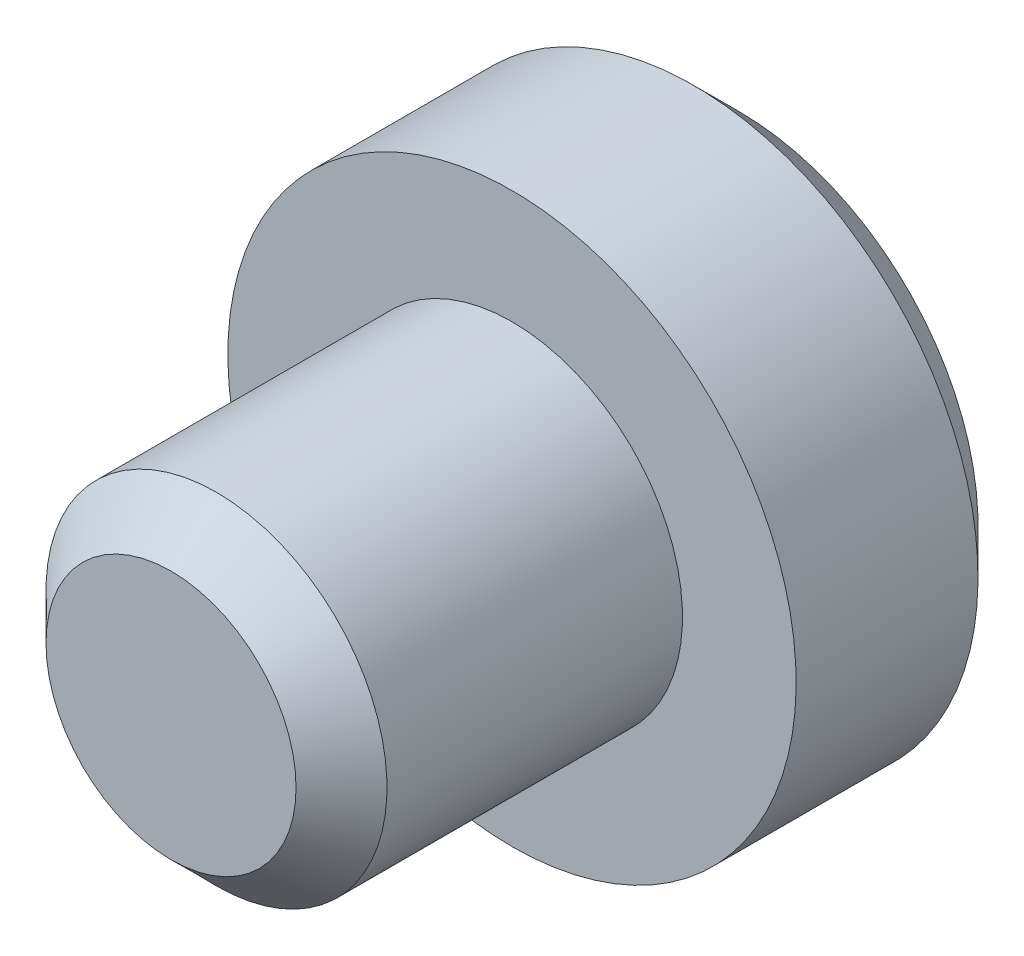
from build123d import *

# Parameters (mm, degrees)
CUT_EXTRUDE1_DEPTH = 2
CHAMFER1_SIZE      = 0.4
CHAMFER2_SIZE      = 0.1
SCALE_1_SCALE      = 0.894736842


with BuildPart() as part:
    # Sketch2 → Revolve1 (revolve)
    with BuildSketch(Plane(origin=(0, 0, 0), x_dir=(0, 0, -1), z_dir=(1, 0, 0))):
        Polygon((0, 2.5), (-2, 2.5), (-2, 1.5), (-5, 1.5), (-5, 0), (0, 0), align=None)
    revolve(axis=Axis((0, 0, 5), (0, 0, -1)))

    # Sketch3 → Cut-Extrude1 (cut)
    with BuildSketch(Plane(origin=(0, 0, 0), x_dir=(-1, 0, 0), z_dir=(0, 0, -1))):
        Polygon((1.168445951, -0.498063644), (1.015558744, 0.762872054), (-0.152887207, 1.260935698), (-1.168445951, 0.498063644), (-1.015558744, -0.762872054), (0.152887207, -1.260935698), align=None)
    extrude(amount=-CUT_EXTRUDE1_DEPTH, mode=Mode.SUBTRACT)

    # Chamfer1
    chamfer1_edges = [part.edges().sort_by_distance(p)[0] for p in [
        (0, -1.5, 5),
        (0, -2.5, 0),
    ]]
    chamfer(chamfer1_edges, length=CHAMFER1_SIZE)

    # Chamfer2
    chamfer2_edges = [part.edges().sort_by_distance(p)[0] for p in [
        (-0.660666579, -0.879499671, 0),
        (-1.092002347, 0.132404205, 0),
        (-0.431335769, 1.011903876, 0),
        (0.660666579, 0.879499671, 0),
        (1.092002347, -0.132404205, 0),
        (0.431335769, -1.011903876, 0),
    ]]
    chamfer(chamfer2_edges, length=CHAMFER2_SIZE)


with BuildPart() as part_1:
    # ｽｹｰﾙ1: scaled about (0, 0, 2.024919763)
    add(part.part.scale(SCALE_1_SCALE).moved(Location((0, 0, 0.213149449))))


solid = part_1.part
